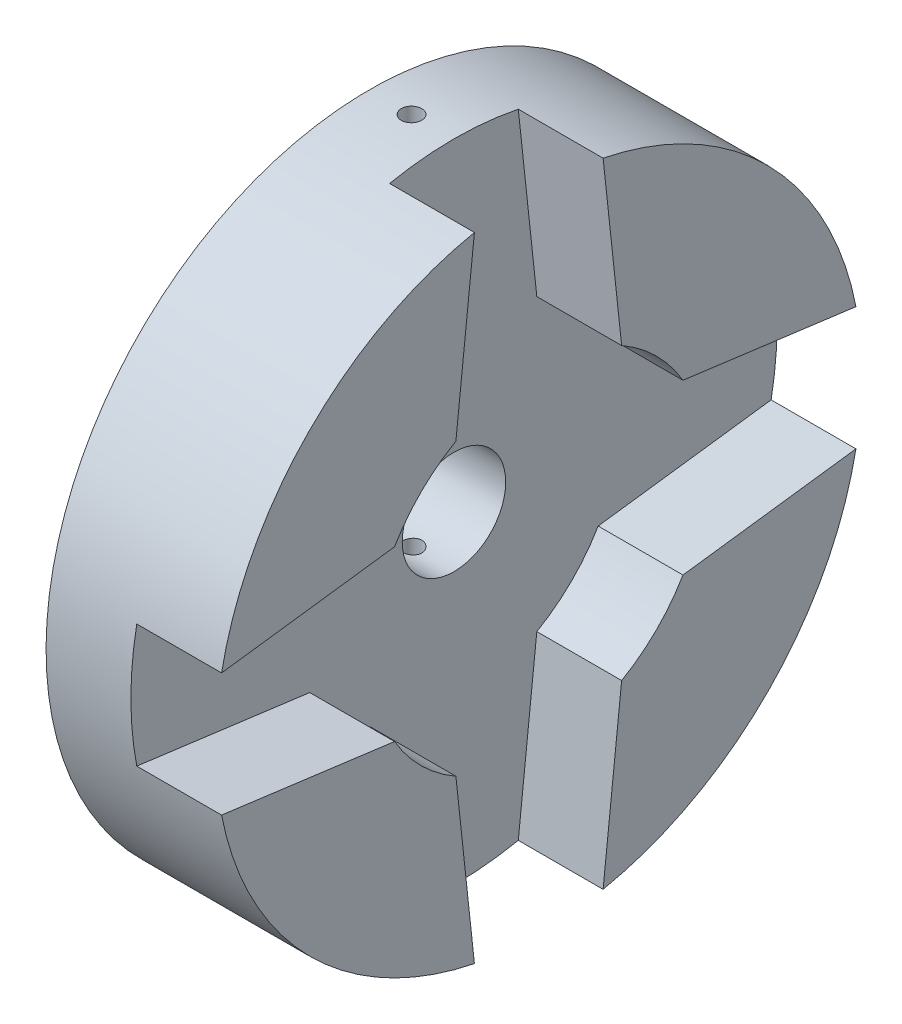
from build123d import *

# Parameters (mm, degrees)
SKETCH2_R           = 19.05
BOSS_EXTRUDE1_DEPTH = 5
BOSS_EXTRUDE2_DEPTH = 5
SKETCH6_R           = 3.05
CUT_EXTRUDE1_DEPTH  = 25
SKETCH8_R           = 0.6
CUT_EXTRUDE4_DEPTH  = 25


with BuildPart() as part:
    # Sketch2 → Boss-Extrude1 (new body)
    with BuildSketch(Plane(origin=(0, 0, 0), x_dir=(0, 0, -1), z_dir=(1, 0, 0))):
        Circle(SKETCH2_R)
    extrude(amount=BOSS_EXTRUDE1_DEPTH)

    # Sketch4 → Boss-Extrude2 (add)
    with BuildSketch(Plane(origin=(5, 0, 0), x_dir=(0, 0, -1), z_dir=(1, 0, 0))):
        with BuildLine():
            Line((4.886596437, 8.552407571), (3.793697076, 18.668432245))
            ThreePointArc((3.793697076, 18.668432245), (13.529522994, 13.410984586), (18.701093352, 3.629270922))
            Line((18.701093352, 3.629270922), (8.502967267, 4.972127076))
            ThreePointArc((8.502967267, 4.972127076), (6.929986014, 6.999842416), (4.886596437, 8.552407571))
        make_face()
        with BuildLine():
            Line((-4.886596437, 8.552407571), (-3.793697076, 18.668432245))
            ThreePointArc((-3.793697076, 18.668432245), (-13.529522994, 13.410984586), (-18.701093352, 3.629270922))
            Line((-18.701093352, 3.629270922), (-8.502967267, 4.972127076))
            ThreePointArc((-8.502967267, 4.972127076), (-6.929986014, 6.999842416), (-4.886596437, 8.552407571))
        make_face()
        with BuildLine():
            Line((-8.502967267, -4.972127076), (-18.701093352, -3.629270922))
            ThreePointArc((-18.701093352, -3.629270922), (-13.529522994, -13.410984586), (-3.793697076, -18.668432245))
            Line((-3.793697076, -18.668432245), (-4.886596437, -8.552407571))
            ThreePointArc((-4.886596437, -8.552407571), (-6.929986014, -6.999842416), (-8.502967267, -4.972127076))
        make_face()
        with BuildLine():
            Line((4.886596437, -8.552407571), (3.793697076, -18.668432245))
            ThreePointArc((3.793697076, -18.668432245), (13.529522994, -13.410984586), (18.701093352, -3.629270922))
            Line((18.701093352, -3.629270922), (8.502967267, -4.972127076))
            ThreePointArc((8.502967267, -4.972127076), (6.929986014, -6.999842416), (4.886596437, -8.552407571))
        make_face()
    extrude(amount=BOSS_EXTRUDE2_DEPTH)

    # Sketch6 → Cut-Extrude1 (cut)
    with BuildSketch(Plane.ZY):
        Circle(SKETCH6_R)
    extrude(amount=-CUT_EXTRUDE1_DEPTH, mode=Mode.SUBTRACT)

    # Sketch8 → Cut-Extrude4 (cut, symmetric)
    with BuildSketch(Plane(origin=(0, 0, 0), x_dir=(1, 0, 0), z_dir=(0, 1, 0))):
        with Locations((2.5, 0)):
            Circle(SKETCH8_R)
    extrude(amount=CUT_EXTRUDE4_DEPTH, both=True, mode=Mode.SUBTRACT)


solid = part.part
